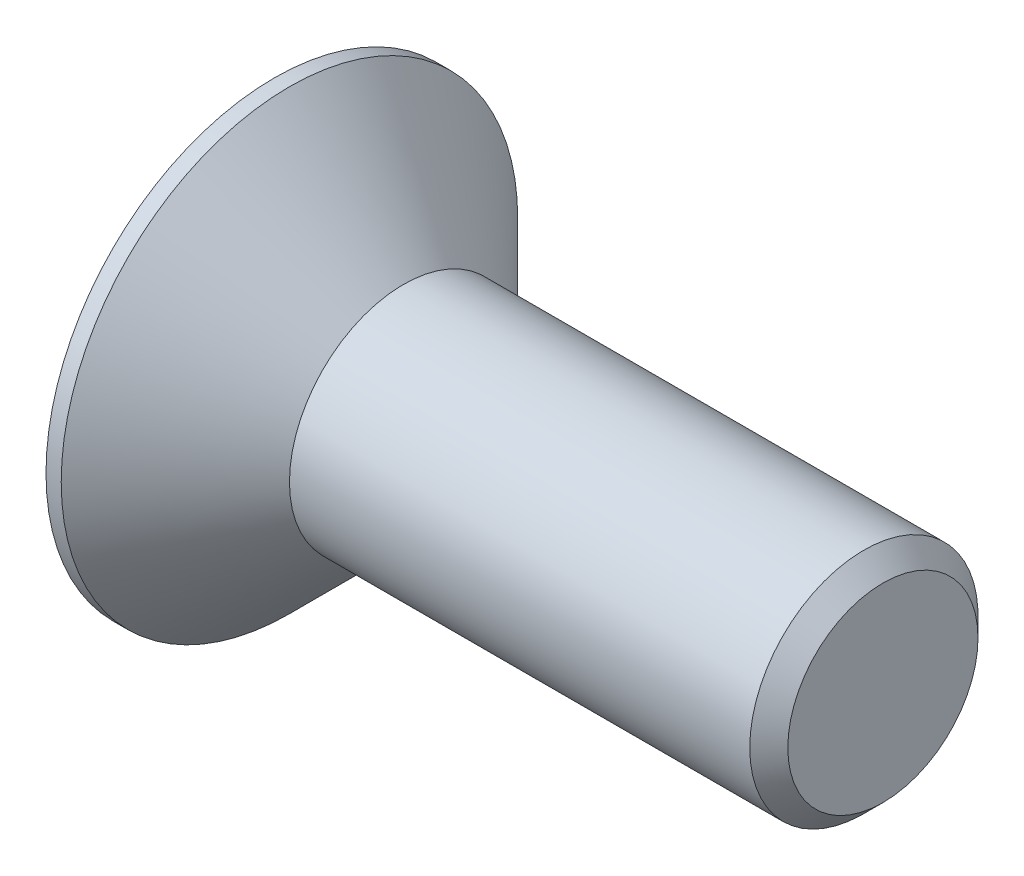
from build123d import *

# Parameters (mm, degrees)
CUT_EXTRUDE1_DEPTH = 0.8


with BuildPart() as part:
    # Sketch2 → Revolve1 (revolve)
    with BuildSketch(Plane.XY):
        Polygon((0, 0), (0, 3), (0.2, 3), (1.7, 1.5), (7.75, 1.5), (8, 1.25), (8, 0), align=None)
    revolve(axis=Axis((-2.281841559, 0, 0), (1, 0, 0)))

    # Sketch3 → Cut-Extrude1 (cut)
    with BuildSketch(Plane.ZY):
        Polygon((0.721687836, -1.25), (1.443375673, 0), (0.721687836, 1.25), (-0.721687836, 1.25), (-1.443375673, 0), (-0.721687836, -1.25), align=None)
    extrude(amount=-CUT_EXTRUDE1_DEPTH, mode=Mode.SUBTRACT)


solid = part.part
